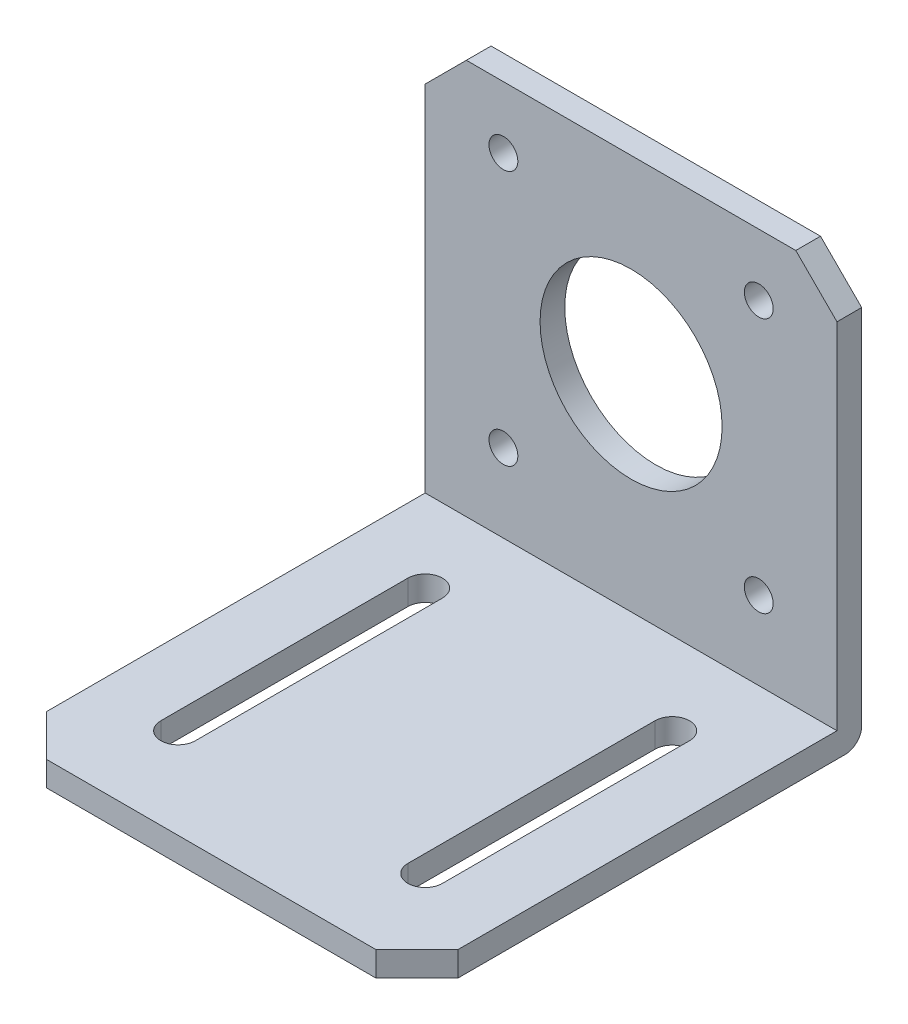
from build123d import *

# Parameters (mm, degrees)
SKETCH_1_R          = 1.75
SKETCH_1_R_2        = 11.05
EXTRUDE_1_DEPTH     = 3
SKETCH_2_W          = 50
SKETCH_2_H          = 3
EXTRUDE_2_DEPTH     = 51
FILLET_1_R          = 2
CUT_EXTRUDE_1_DEPTH = 51
CHAMFER_1_SIZE      = 5


with BuildPart() as part:
    # 草图1 → 凸台-拉伸1 (new body)
    with BuildSketch(Plane.XY):
        Polygon((25, 29.708680022), (25, -16.291319978), (-25, -16.291319978), (-25, 29.708680022), (-20, 34.708680022), (20, 34.708680022), align=None)
        with Locations((-15.5, 27.208680022)):
            Circle(SKETCH_1_R, mode=Mode.SUBTRACT)
        with Locations((15.5, 27.208680022)):
            Circle(SKETCH_1_R, mode=Mode.SUBTRACT)
        with Locations((-15.5, -3.791319978)):
            Circle(SKETCH_1_R, mode=Mode.SUBTRACT)
        with Locations((15.5, -3.791319978)):
            Circle(SKETCH_1_R, mode=Mode.SUBTRACT)
        with Locations((0, 11.708680022)):
            Circle(SKETCH_1_R_2, mode=Mode.SUBTRACT)
    extrude(amount=EXTRUDE_1_DEPTH)

    # 草图2 → 凸台-拉伸2 (add)
    with BuildSketch(Plane.XY.offset(3)):
        with Locations((0, -14.791319978)):
            Rectangle(SKETCH_2_W, SKETCH_2_H)
    extrude(amount=EXTRUDE_2_DEPTH)

    # 圆角1
    fillet_1_edges = [part.edges().sort_by_distance(p)[0] for p in [
        (0, -16.291319978, 0),
    ]]
    fillet(fillet_1_edges, radius=FILLET_1_R)

    # 草图3 → 切除-拉伸1 (cut)
    with BuildSketch(Plane(origin=(0, -13.291319978, 0), x_dir=(1, 0, 0), z_dir=(0, 1, 0))):
        with BuildLine():
            Line((-17.1, -13), (-17.1, -43))
            ThreePointArc((-17.1, -43), (-15, -45.1), (-12.9, -43))
            Line((-12.9, -43), (-12.9, -13))
            ThreePointArc((-12.9, -13), (-15, -10.9), (-17.1, -13))
        make_face()
        with BuildLine():
            Line((12.9, -13), (12.9, -43))
            ThreePointArc((12.9, -43), (15, -45.1), (17.1, -43))
            Line((17.1, -43), (17.1, -13))
            ThreePointArc((17.1, -13), (15, -10.9), (12.9, -13))
        make_face()
    extrude(amount=-CUT_EXTRUDE_1_DEPTH, mode=Mode.SUBTRACT)

    # 倒角1
    chamfer_1_edges = [part.edges().sort_by_distance(p)[0] for p in [
        (-25, -14.791319978, 54),
        (25, -14.791319978, 54),
    ]]
    chamfer(chamfer_1_edges, length=CHAMFER_1_SIZE)


solid = part.part
